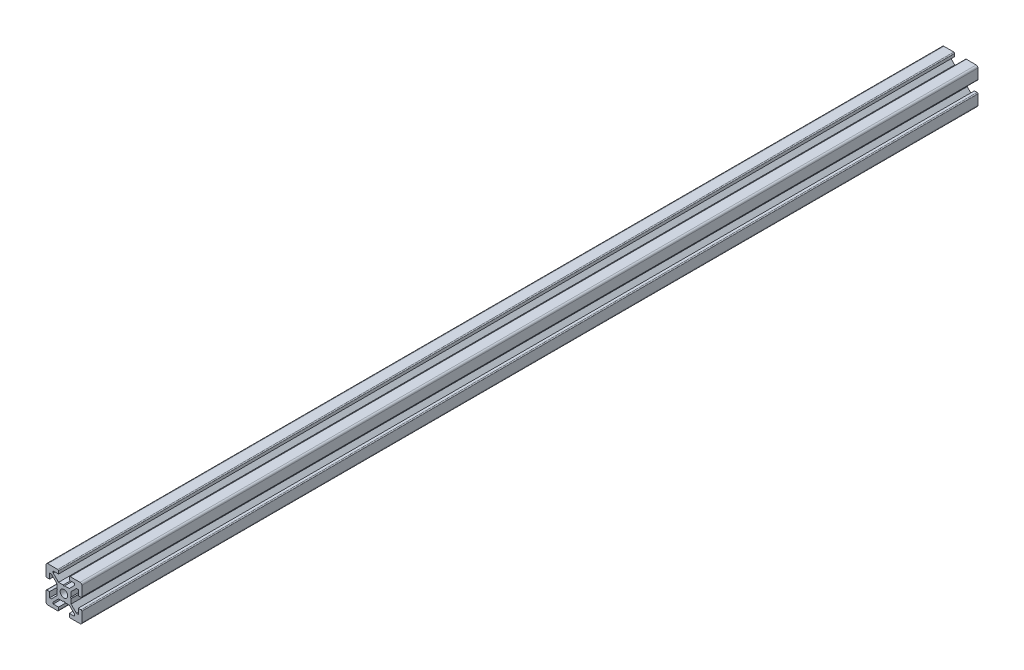
from build123d import *

# Parameters (mm, degrees)
SCHIZZO1_R                   = 2.1
ESTRUSIONE_ESTRUSIONE1_DEPTH = 500
SCHIZZO2_R                   = 3
TAGLIO_ESTRUSIONE1_DEPTH     = 15


with BuildPart() as part:
    # Schizzo1 → Estrusione-Estrusione1 (new body)
    with BuildSketch(Plane.XY):
        with BuildLine():
            Line((-3.6, 0), (-4, 0.4))
            Line((-4, 0.4), (-4, 3))
            Line((-4, 3), (-7, 6))
            Line((-7, 6), (-8, 6))
            Line((-8, 6), (-8, 3))
            Line((-8, 3), (-9.5, 3))
            ThreePointArc((-9.5, 3), (-9.853553391, 3.146446609), (-10, 3.5))
            Line((-10, 3.5), (-10, 9))
            ThreePointArc((-10, 9), (-9.707106781, 9.707106781), (-9, 10))
            Line((-9, 10), (-3.5, 10))
            ThreePointArc((-3.5, 10), (-3.146446609, 9.853553391), (-3, 9.5))
            Line((-3, 9.5), (-3, 8))
            Line((-3, 8), (-6, 8))
            Line((-6, 8), (-6, 7))
            Line((-6, 7), (-3, 4))
            Line((-3, 4), (-0.4, 4))
            Line((-0.4, 4), (0, 3.6))
            Line((0, 3.6), (0.4, 4))
            Line((0.4, 4), (3, 4))
            Line((3, 4), (6, 7))
            Line((6, 7), (6, 8))
            Line((6, 8), (3, 8))
            Line((3, 8), (3, 9.5))
            ThreePointArc((3, 9.5), (3.146446609, 9.853553391), (3.5, 10))
            Line((3.5, 10), (9, 10))
            ThreePointArc((9, 10), (9.707106781, 9.707106781), (10, 9))
            Line((10, 9), (10, 3.5))
            ThreePointArc((10, 3.5), (9.853553391, 3.146446609), (9.5, 3))
            Line((9.5, 3), (8, 3))
            Line((8, 3), (8, 6))
            Line((8, 6), (7, 6))
            Line((7, 6), (4, 3))
            Line((4, 3), (4, 0.4))
            Line((4, 0.4), (3.6, 0))
            Line((3.6, 0), (4, -0.4))
            Line((4, -0.4), (4, -3))
            Line((4, -3), (7, -6))
            Line((7, -6), (8, -6))
            Line((8, -6), (8, -3))
            Line((8, -3), (9.5, -3))
            ThreePointArc((9.5, -3), (9.853553391, -3.146446609), (10, -3.5))
            Line((10, -3.5), (10, -9))
            ThreePointArc((10, -9), (9.707106781, -9.707106781), (9, -10))
            Line((9, -10), (3.5, -10))
            ThreePointArc((3.5, -10), (3.146446609, -9.853553391), (3, -9.5))
            Line((3, -9.5), (3, -8))
            Line((3, -8), (6, -8))
            Line((6, -8), (6, -7))
            Line((6, -7), (3, -4))
            Line((3, -4), (0.4, -4))
            Line((0.4, -4), (0, -3.6))
            Line((0, -3.6), (-0.4, -4))
            Line((-0.4, -4), (-3, -4))
            Line((-3, -4), (-6, -7))
            Line((-6, -7), (-6, -8))
            Line((-6, -8), (-3, -8))
            Line((-3, -8), (-3, -9.5))
            ThreePointArc((-3, -9.5), (-3.146446609, -9.853553391), (-3.5, -10))
            Line((-3.5, -10), (-9, -10))
            ThreePointArc((-9, -10), (-9.707106781, -9.707106781), (-10, -9))
            Line((-10, -9), (-10, -3.5))
            ThreePointArc((-10, -3.5), (-9.853553391, -3.146446609), (-9.5, -3))
            Line((-9.5, -3), (-8, -3))
            Line((-8, -3), (-8, -6))
            Line((-8, -6), (-7, -6))
            Line((-7, -6), (-4, -3))
            Line((-4, -3), (-4, -0.4))
            Line((-4, -0.4), (-3.6, 0))
        make_face()
        Circle(SCHIZZO1_R, mode=Mode.SUBTRACT)
    extrude(amount=ESTRUSIONE_ESTRUSIONE1_DEPTH)

    # Schizzo2 → Taglio-Estrusione1 (cut, through all)
    with BuildSketch(Plane.ZY.offset(4)):
        with Locations((25, 0)):
            Circle(SCHIZZO2_R)
        with Locations((475, 0)):
            Circle(SCHIZZO2_R)
    extrude(amount=-TAGLIO_ESTRUSIONE1_DEPTH, mode=Mode.SUBTRACT)


solid = part.part
